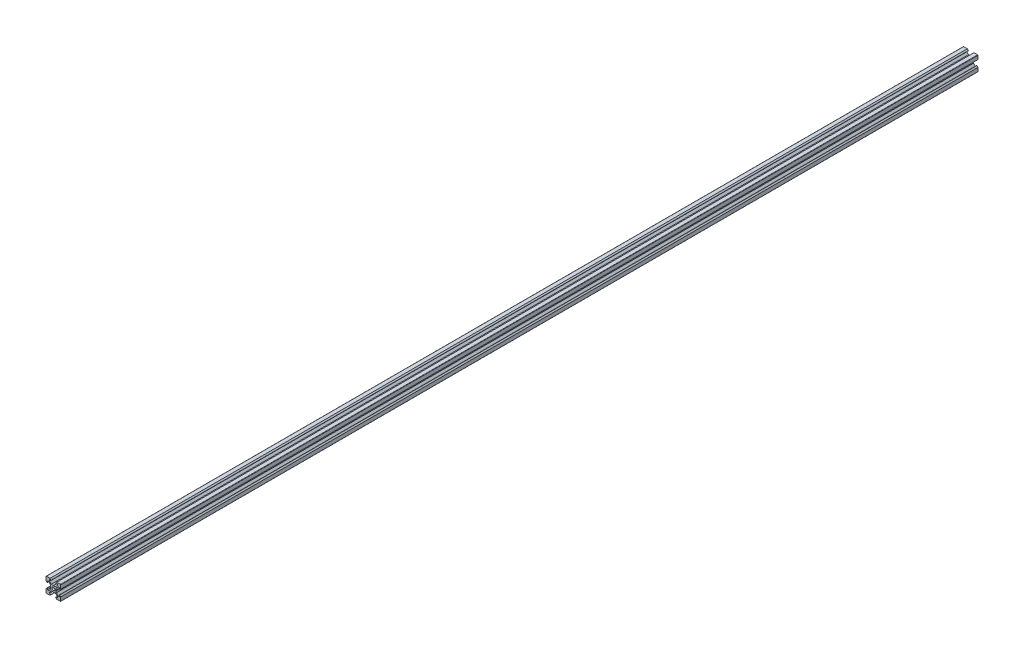
from build123d import *

# Parameters (mm, degrees)
SKETCH1_R           = 2.1
BOSS_EXTRUDE1_DEPTH = 1244


with BuildPart() as part:
    # Sketch1 → Boss-Extrude1 (new body)
    with BuildSketch(Plane.XY):
        with BuildLine():
            Line((4.58, -10), (9.5, -10))
            ThreePointArc((9.5, -10), (9.853553391, -9.853553391), (10, -9.5))
            Line((10, -9.5), (10, -4.58))
            Line((10, -4.58), (8.545, -3.125))
            Line((8.545, -3.125), (8.2, -3.125))
            Line((8.2, -3.125), (8.2, -5.5))
            Line((8.2, -5.5), (6.560660172, -5.5))
            Line((6.560660172, -5.5), (3.9, -2.839339828))
            Line((3.9, -2.839339828), (3.9, -0.21))
            Line((3.9, -0.21), (3.69, 0))
            Line((3.69, 0), (3.9, 0.21))
            Line((3.9, 0.21), (3.9, 2.839339828))
            Line((3.9, 2.839339828), (6.560660172, 5.5))
            Line((6.560660172, 5.5), (8.2, 5.5))
            Line((8.2, 5.5), (8.2, 3.125))
            Line((8.2, 3.125), (8.545, 3.125))
            Line((8.545, 3.125), (10, 4.58))
            Line((10, 4.58), (10, 9.5))
            ThreePointArc((10, 9.5), (9.853553391, 9.853553391), (9.5, 10))
            Line((9.5, 10), (4.58, 10))
            Line((4.58, 10), (3.125, 8.545))
            Line((3.125, 8.545), (3.125, 8.2))
            Line((3.125, 8.2), (5.5, 8.2))
            Line((5.5, 8.2), (5.5, 6.560660172))
            Line((5.5, 6.560660172), (2.839339828, 3.9))
            Line((2.839339828, 3.9), (0.21, 3.9))
            Line((0.21, 3.9), (0, 3.69))
            Line((0, 3.69), (-0.21, 3.9))
            Line((-0.21, 3.9), (-2.839339828, 3.9))
            Line((-2.839339828, 3.9), (-5.5, 6.560660172))
            Line((-5.5, 6.560660172), (-5.5, 8.2))
            Line((-5.5, 8.2), (-3.125, 8.2))
            Line((-3.125, 8.2), (-3.125, 8.545))
            Line((-3.125, 8.545), (-4.58, 10))
            Line((-4.58, 10), (-9.5, 10))
            ThreePointArc((-9.5, 10), (-9.853553391, 9.853553391), (-10, 9.5))
            Line((-10, 9.5), (-10, 4.58))
            Line((-10, 4.58), (-8.545, 3.125))
            Line((-8.545, 3.125), (-8.2, 3.125))
            Line((-8.2, 3.125), (-8.2, 5.5))
            Line((-8.2, 5.5), (-6.560660172, 5.5))
            Line((-6.560660172, 5.5), (-3.9, 2.839339828))
            Line((-3.9, 2.839339828), (-3.9, 0.21))
            Line((-3.9, 0.21), (-3.69, 0))
            Line((-3.69, 0), (-3.9, -0.21))
            Line((-3.9, -0.21), (-3.9, -2.839339828))
            Line((-3.9, -2.839339828), (-6.560660172, -5.5))
            Line((-6.560660172, -5.5), (-8.2, -5.5))
            Line((-8.2, -5.5), (-8.2, -3.125))
            Line((-8.2, -3.125), (-8.545, -3.125))
            Line((-8.545, -3.125), (-10, -4.58))
            Line((-10, -4.58), (-10, -9.5))
            ThreePointArc((-10, -9.5), (-9.853553391, -9.853553391), (-9.5, -10))
            Line((-9.5, -10), (-4.58, -10))
            Line((-4.58, -10), (-3.125, -8.545))
            Line((-3.125, -8.545), (-3.125, -8.2))
            Line((-3.125, -8.2), (-5.5, -8.2))
            Line((-5.5, -8.2), (-5.5, -6.560660172))
            Line((-5.5, -6.560660172), (-2.839339828, -3.9))
            Line((-2.839339828, -3.9), (-0.21, -3.9))
            Line((-0.21, -3.9), (0, -3.69))
            Line((0, -3.69), (0.21, -3.9))
            Line((0.21, -3.9), (2.839339828, -3.9))
            Line((2.839339828, -3.9), (5.5, -6.560660172))
            Line((5.5, -6.560660172), (5.5, -8.2))
            Line((5.5, -8.2), (3.125, -8.2))
            Line((3.125, -8.2), (3.125, -8.545))
            Line((3.125, -8.545), (4.58, -10))
        make_face()
        Circle(SKETCH1_R, mode=Mode.SUBTRACT)
    extrude(amount=BOSS_EXTRUDE1_DEPTH)


solid = part.part
